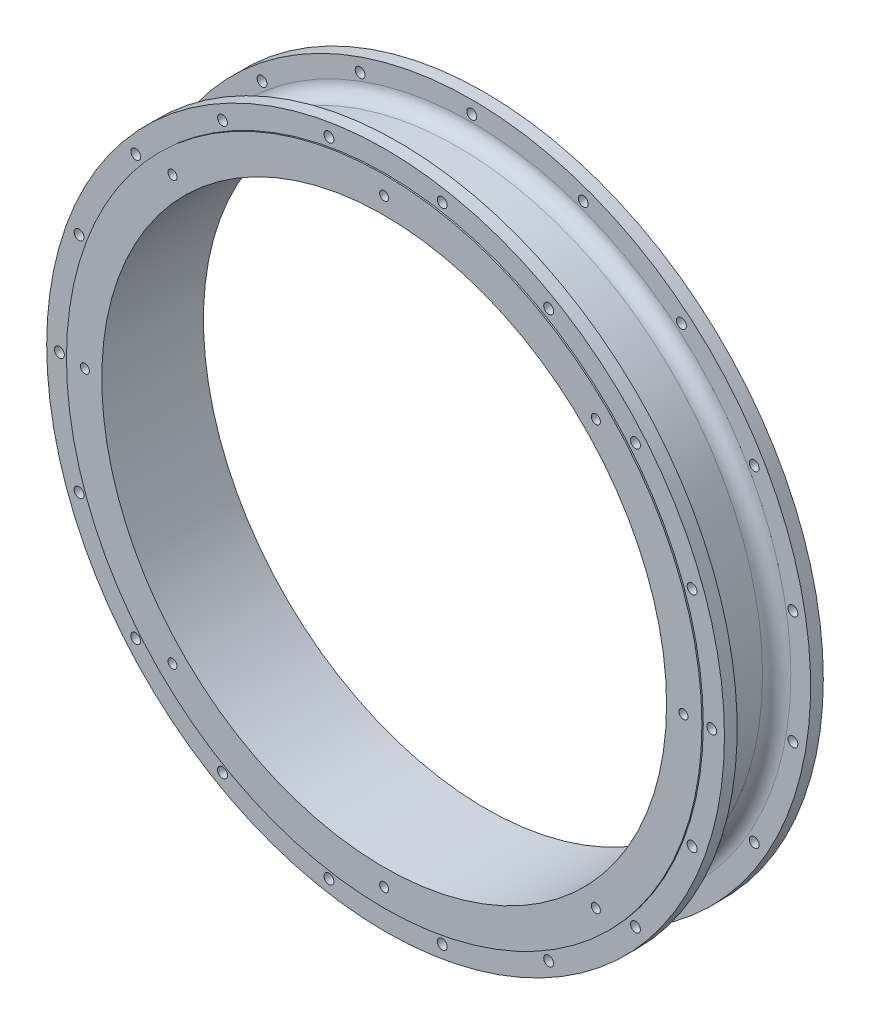
from build123d import *

# Parameters (mm, degrees)
SKETCH_1_R               = 120
EXTRUDE_1_DEPTH          = 35
SKETCH_9_R               = 112.5
EXTRUDE_2_DEPTH          = 0.5
SKETCH_6_R               = 112.5
EXTRUDE_3_DEPTH          = 0.5
SKETCH_5_R               = 100
CUT_EXTRUDE_2_DEPTH      = 1.5
CUT_EXTRUDE_2_DEPTH_BACK = 36.5
SKETCH_4_R               = 1.75
CUT_EXTRUDE_3_DEPTH      = 5
SKETCH_2_R               = 1.75
CUT_EXTRUDE_4_DEPTH      = 5
SKETCH_10_R              = 1.6
CUT_EXTRUDE_6_DEPTH      = 6
CUT_EXTRUDE_START        = 36
SKETCH_11_R              = 1.6
CUT_EXTRUDE_7_DEPTH      = 6.5


with BuildPart() as part:
    # Эскиз1 → Бобышка-Вытянуть1 (new body)
    with BuildSketch(Plane.XY):
        Circle(SKETCH_1_R)
    extrude(amount=EXTRUDE_1_DEPTH)

    # Эскиз7 → Вырез-Повернуть2 (revolve, cut)
    with BuildSketch(Plane(origin=(0, 0, 0), x_dir=(1, 0, 0), z_dir=(0, 1, 0))):
        with BuildLine():
            Line((-120, 0), (-120, -4.5))
            Line((-120, -4.5), (-113, -4.5))
            ThreePointArc((-113, -4.5), (-109.464466094, -5.964466094), (-108, -9.5))
            Line((-108, -9.5), (-108, -25.5))
            ThreePointArc((-108, -25.5), (-109.464466094, -29.035533906), (-113, -30.5))
            Line((-113, -30.5), (-120, -30.5))
            Line((-120, -30.5), (-120, -35))
            Line((-120, -35), (-128.220660741, -35))
            Line((-128.220660741, -35), (-128.220660741, 0))
            Line((-128.220660741, 0), (-120, 0))
        make_face()
    revolve(axis=Axis((0, 0, 0), (0, 0, 1)), mode=Mode.SUBTRACT)

    # Эскиз9 → Бобышка-Вытянуть2 (add)
    with BuildSketch(Plane.XY.offset(35)):
        Circle(SKETCH_9_R)
    extrude(amount=EXTRUDE_2_DEPTH)

    # Эскиз6 → Бобышка-Вытянуть3 (add)
    with BuildSketch(Plane(origin=(0, 0, 0), x_dir=(-1, 0, 0), z_dir=(0, 0, -1))):
        Circle(SKETCH_6_R)
    extrude(amount=EXTRUDE_3_DEPTH)

    # Эскиз5 → Вырез-Вытянуть2 (cut, two sides)
    with BuildSketch(Plane.XY.offset(35)) as cut_extrude_2_sk:
        Circle(SKETCH_5_R)
    extrude(amount=CUT_EXTRUDE_2_DEPTH, mode=Mode.SUBTRACT)
    extrude(cut_extrude_2_sk.sketch, amount=-CUT_EXTRUDE_2_DEPTH_BACK, mode=Mode.SUBTRACT)

    # Эскиз4 → Вырез-Вытянуть3 (cut)
    with BuildSketch(Plane.XY.offset(35)):
        with Locations((-115.5, 0)):
            Circle(SKETCH_4_R)
        with Locations((-108.534497701, 39.503326554)):
            Circle(SKETCH_4_R)
        with Locations((-88.47813318, 74.241968919)):
            Circle(SKETCH_4_R)
        with Locations((-57.75, 100.025934137)):
            Circle(SKETCH_4_R)
        with Locations((-20.056364521, 113.745295473)):
            Circle(SKETCH_4_R)
        with Locations((20.056364521, 113.745295473)):
            Circle(SKETCH_4_R)
        with Locations((57.75, 100.025934137)):
            Circle(SKETCH_4_R)
        with Locations((88.47813318, 74.241968919)):
            Circle(SKETCH_4_R)
        with Locations((108.534497701, 39.503326554)):
            Circle(SKETCH_4_R)
        with Locations((115.5, 0)):
            Circle(SKETCH_4_R)
        with Locations((108.534497701, -39.503326554)):
            Circle(SKETCH_4_R)
        with Locations((88.47813318, -74.241968919)):
            Circle(SKETCH_4_R)
        with Locations((57.75, -100.025934137)):
            Circle(SKETCH_4_R)
        with Locations((20.056364521, -113.745295473)):
            Circle(SKETCH_4_R)
        with Locations((-20.056364521, -113.745295473)):
            Circle(SKETCH_4_R)
        with Locations((-57.75, -100.025934137)):
            Circle(SKETCH_4_R)
        with Locations((-88.47813318, -74.241968919)):
            Circle(SKETCH_4_R)
        with Locations((-108.534497701, -39.503326554)):
            Circle(SKETCH_4_R)
    extrude(amount=-CUT_EXTRUDE_3_DEPTH, mode=Mode.SUBTRACT)

    # Эскиз2 → Вырез-Вытянуть4 (cut)
    with BuildSketch(Plane(origin=(0, 0, 0), x_dir=(-1, 0, 0), z_dir=(0, 0, -1))):
        with Locations((0, 115.5)):
            Circle(SKETCH_2_R)
        with Locations((39.503326554, 108.534497701)):
            Circle(SKETCH_2_R)
        with Locations((74.241968919, 88.47813318)):
            Circle(SKETCH_2_R)
        with Locations((100.025934137, 57.75)):
            Circle(SKETCH_2_R)
        with Locations((113.745295473, 20.056364521)):
            Circle(SKETCH_2_R)
        with Locations((113.745295473, -20.056364521)):
            Circle(SKETCH_2_R)
        with Locations((100.025934137, -57.75)):
            Circle(SKETCH_2_R)
        with Locations((74.241968919, -88.47813318)):
            Circle(SKETCH_2_R)
        with Locations((39.503326554, -108.534497701)):
            Circle(SKETCH_2_R)
        with Locations((0, -115.5)):
            Circle(SKETCH_2_R)
        with Locations((-39.503326554, -108.534497701)):
            Circle(SKETCH_2_R)
        with Locations((-74.241968919, -88.47813318)):
            Circle(SKETCH_2_R)
        with Locations((-100.025934137, -57.75)):
            Circle(SKETCH_2_R)
        with Locations((-113.745295473, -20.056364521)):
            Circle(SKETCH_2_R)
        with Locations((-113.745295473, 20.056364521)):
            Circle(SKETCH_2_R)
        with Locations((-100.025934137, 57.75)):
            Circle(SKETCH_2_R)
        with Locations((-74.241968919, 88.47813318)):
            Circle(SKETCH_2_R)
        with Locations((-39.503326554, 108.534497701)):
            Circle(SKETCH_2_R)
    extrude(amount=-CUT_EXTRUDE_4_DEPTH, mode=Mode.SUBTRACT)

    # Эскиз10 → Вырез-Вытянуть6 (cut)
    with BuildSketch(Plane(origin=(0, 0, -0.5), x_dir=(-1, 0, 0), z_dir=(0, 0, -1))):
        with Locations((0, 106)):
            Circle(SKETCH_10_R)
        with Locations((74.953318806, 74.953318806)):
            Circle(SKETCH_10_R)
        with Locations((106, 0)):
            Circle(SKETCH_10_R)
        with Locations((74.953318806, -74.953318806)):
            Circle(SKETCH_10_R)
        with Locations((0, -106)):
            Circle(SKETCH_10_R)
        with Locations((-74.953318806, -74.953318806)):
            Circle(SKETCH_10_R)
        with Locations((-106, 0)):
            Circle(SKETCH_10_R)
        with Locations((-74.953318806, 74.953318806)):
            Circle(SKETCH_10_R)
    extrude(amount=-CUT_EXTRUDE_6_DEPTH, mode=Mode.SUBTRACT)

    # Эскиз11 → Вырез-Вытянуть7 (cut)
    with BuildSketch(Plane.XY.offset(CUT_EXTRUDE_START)):
        with Locations((0, 106)):
            Circle(SKETCH_11_R)
        with Locations((74.953318806, 74.953318806)):
            Circle(SKETCH_11_R)
        with Locations((106, 0)):
            Circle(SKETCH_11_R)
        with Locations((74.953318806, -74.953318806)):
            Circle(SKETCH_11_R)
        with Locations((0, -106)):
            Circle(SKETCH_11_R)
        with Locations((-74.953318806, -74.953318806)):
            Circle(SKETCH_11_R)
        with Locations((-106, 0)):
            Circle(SKETCH_11_R)
        with Locations((-74.953318806, 74.953318806)):
            Circle(SKETCH_11_R)
    extrude(amount=-CUT_EXTRUDE_7_DEPTH, mode=Mode.SUBTRACT)


solid = part.part
